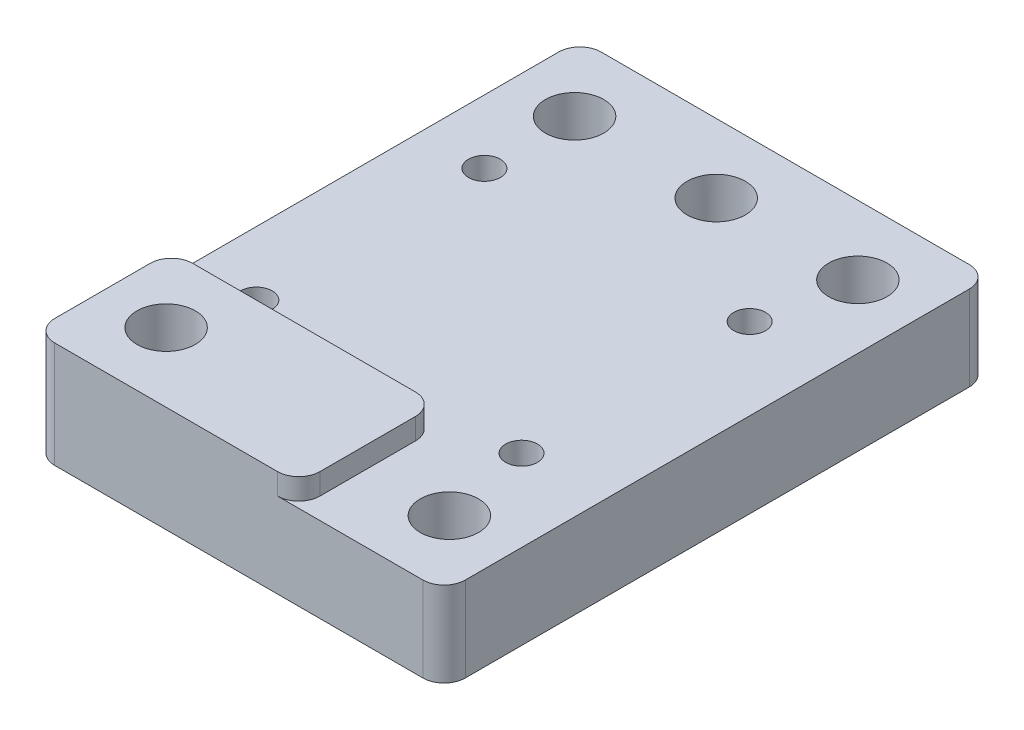
from build123d import *

# Parameters (mm, degrees)
SKETCH1_W               = 38.7
SKETCH1_H               = 51.5
BOSS_EXTRUDE1_DEPTH     = 8
SKETCH2_R               = 1.5
CUT_EXTRUDE1_DEPTH      = 9
SKETCH6_W               = 25
SKETCH6_H               = 13
BOSS_EXTRUDE3_DEPTH     = 2
CUT_EXTRUDE2_START      = -9
SKETCH3_R               = 2.75
CUT_EXTRUDE2_DEPTH      = 12
MIRROR3_START           = -9
MIRROR3_COPY_1_SKETCH_R = 2.75
MIRROR3_COPY_1_DEPTH    = 12
SKETCH4_R               = 2.75
CUT_EXTRUDE3_DEPTH      = 3
CUT_EXTRUDE3_DEPTH_BACK = 9
FILLET1_R               = 2
FILLET2_R               = 2


with BuildPart() as part:
    # Sketch1 → Boss-Extrude1 (new body)
    with BuildSketch(Plane(origin=(0, 0, 0), x_dir=(1, 0, 0), z_dir=(0, 1, 0))):
        Rectangle(SKETCH1_W, SKETCH1_H)
    extrude(amount=BOSS_EXTRUDE1_DEPTH)

    # Sketch2 → Cut-Extrude1 (cut, through all)
    with BuildSketch(Plane(origin=(0, 8, 0), x_dir=(1, 0, 0), z_dir=(0, 1, 0))):
        with Locations((11.65, 10.75)):
            Circle(SKETCH2_R)
        with Locations((-13.35, 10.75)):
            Circle(SKETCH2_R)
    cut_extrude1 = extrude(amount=-CUT_EXTRUDE1_DEPTH, mode=Mode.SUBTRACT)

    # Mirror1: Cut-Extrude1 across plane
    add(cut_extrude1.mirror(Plane.XY), mode=Mode.SUBTRACT)

    # Sketch6 → Boss-Extrude3 (add)
    with BuildSketch(Plane(origin=(0, 8, 0), x_dir=(1, 0, 0), z_dir=(0, 1, 0))):
        with Locations((-6.85, -19.25)):
            Rectangle(SKETCH6_W, SKETCH6_H)
    extrude(amount=BOSS_EXTRUDE3_DEPTH)

    # Sketch3 → Cut-Extrude2 (cut)
    with BuildSketch(Plane(origin=(0, 8, 0), x_dir=(1, 0, 0), z_dir=(0, 1, 0)).offset(CUT_EXTRUDE2_START)):
        with Locations((13.35, -19.25)):
            Circle(SKETCH3_R)
    cut_extrude2 = extrude(amount=CUT_EXTRUDE2_DEPTH, mode=Mode.SUBTRACT)

    # Mirror2: Cut-Extrude2 across plane
    add(cut_extrude2.mirror(Plane(origin=(0, 0, 0), x_dir=(0, 0, 1), z_dir=(1, 0, 0))), mode=Mode.SUBTRACT)

    # Mirror3: Cut-Extrude2 across plane
    add(cut_extrude2.mirror(Plane.XY), mode=Mode.SUBTRACT)

    # Mirror3 copy 1 sketch → Mirror3 copy 1 (cut)
    with BuildSketch(Plane(origin=(0, 8, 0), x_dir=(-1, 0, 0), z_dir=(0, 1, 0)).offset(MIRROR3_START)):
        with Locations((13.35, -19.25)):
            Circle(MIRROR3_COPY_1_SKETCH_R)
    extrude(amount=MIRROR3_COPY_1_DEPTH, mode=Mode.SUBTRACT)

    # Sketch4 → Cut-Extrude3 (cut, two sides)
    with BuildSketch(Plane(origin=(0, 8, 0), x_dir=(1, 0, 0), z_dir=(0, 1, 0))) as cut_extrude3_sk:
        with Locations((0, 19.25)):
            Circle(SKETCH4_R)
    extrude(amount=CUT_EXTRUDE3_DEPTH, mode=Mode.SUBTRACT)
    extrude(cut_extrude3_sk.sketch, amount=-CUT_EXTRUDE3_DEPTH_BACK, mode=Mode.SUBTRACT)

    # Fillet1
    fillet1_edges = [part.edges().sort_by_distance(p)[0] for p in [
        (5.65, 9, 25.75),
        (5.65, 9, 12.75),
        (-19.35, 9, 12.75),
    ]]
    fillet(fillet1_edges, radius=FILLET1_R)

    # Fillet2
    fillet2_edges = [part.edges().sort_by_distance(p)[0] for p in [
        (19.35, 4, 25.75),
        (-19.35, 5, 25.75),
        (-19.35, 4, -25.75),
        (19.35, 4, -25.75),
    ]]
    fillet(fillet2_edges, radius=FILLET2_R)


solid = part.part
